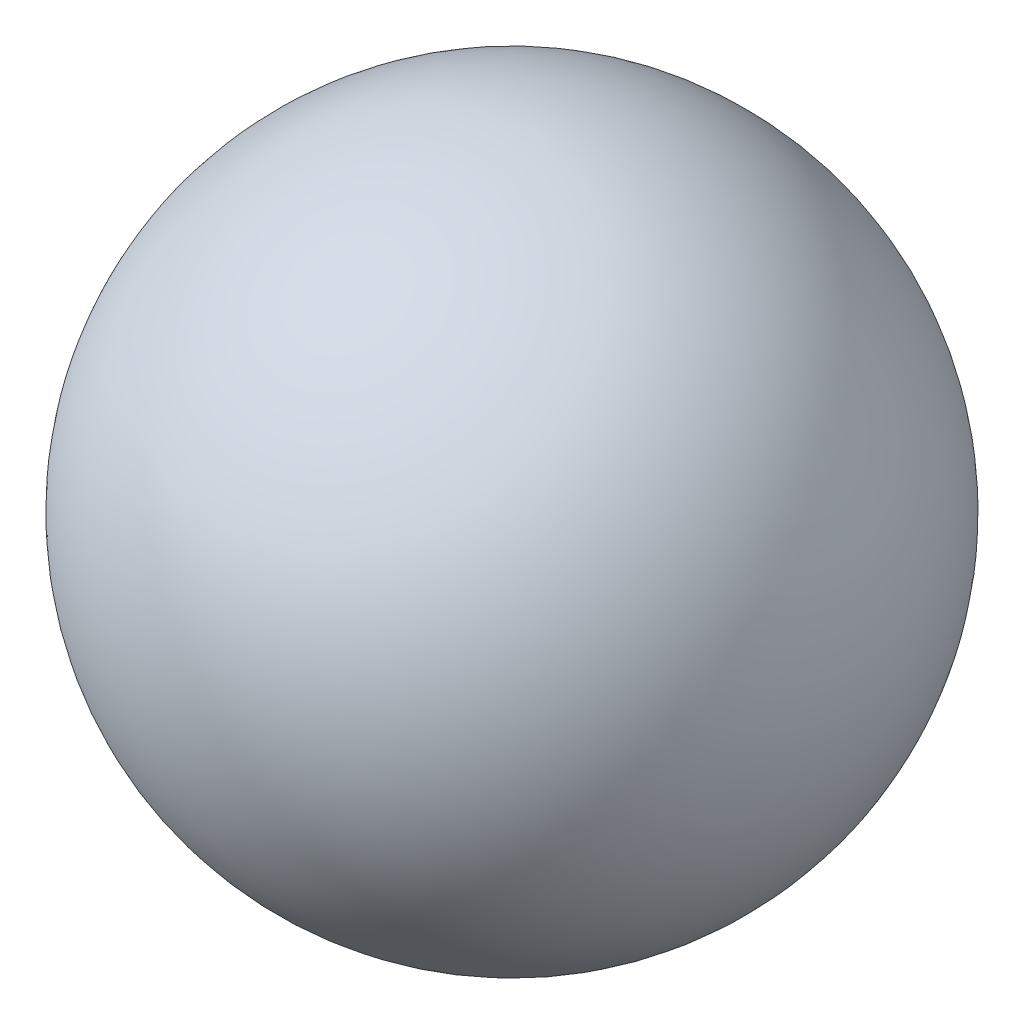
from build123d import *


with BuildPart() as part:
    # Sketch2 → Revolve1 (revolve)
    with BuildSketch(Plane.XY):
        with BuildLine():
            Line((-88.9, 0), (88.9, 0))
            ThreePointArc((88.9, 0), (0, 88.9), (-88.9, 0))
        make_face()
    revolve(axis=Axis((-88.9, 0, 0), (1, 0, 0)))


solid = part.part
